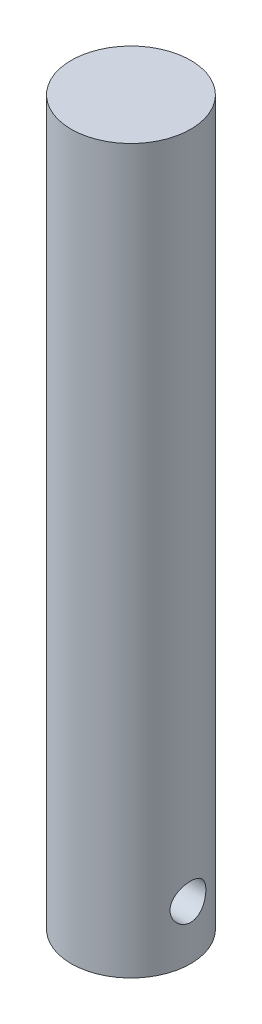
from build123d import *

# Parameters (mm, degrees)
CROQUIS1_R                   = 10
SALIENTE_EXTRUIR1_DEPTH      = 100
SALIENTE_EXTRUIR1_DEPTH_BACK = 21
CROQUIS2_R                   = 3
CORTAR_EXTRUIR1_DEPTH        = 12.5


with BuildPart() as part:
    # Croquis1 → Saliente-Extruir1 (new body, two sides)
    with BuildSketch(Plane(origin=(0, 0, 0), x_dir=(1, 0, 0), z_dir=(0, 1, 0))) as saliente_extruir1_sk:
        Circle(CROQUIS1_R)
    extrude(amount=SALIENTE_EXTRUIR1_DEPTH)
    extrude(saliente_extruir1_sk.sketch, amount=-SALIENTE_EXTRUIR1_DEPTH_BACK)

    # Croquis2 → Cortar-Extruir1 (cut, symmetric)
    with BuildSketch(Plane(origin=(0, 0, 0), x_dir=(0, 0, -1), z_dir=(1, 0, 0))):
        with Locations((0, -12)):
            Circle(CROQUIS2_R)
    extrude(amount=CORTAR_EXTRUIR1_DEPTH, both=True, mode=Mode.SUBTRACT)


solid = part.part
